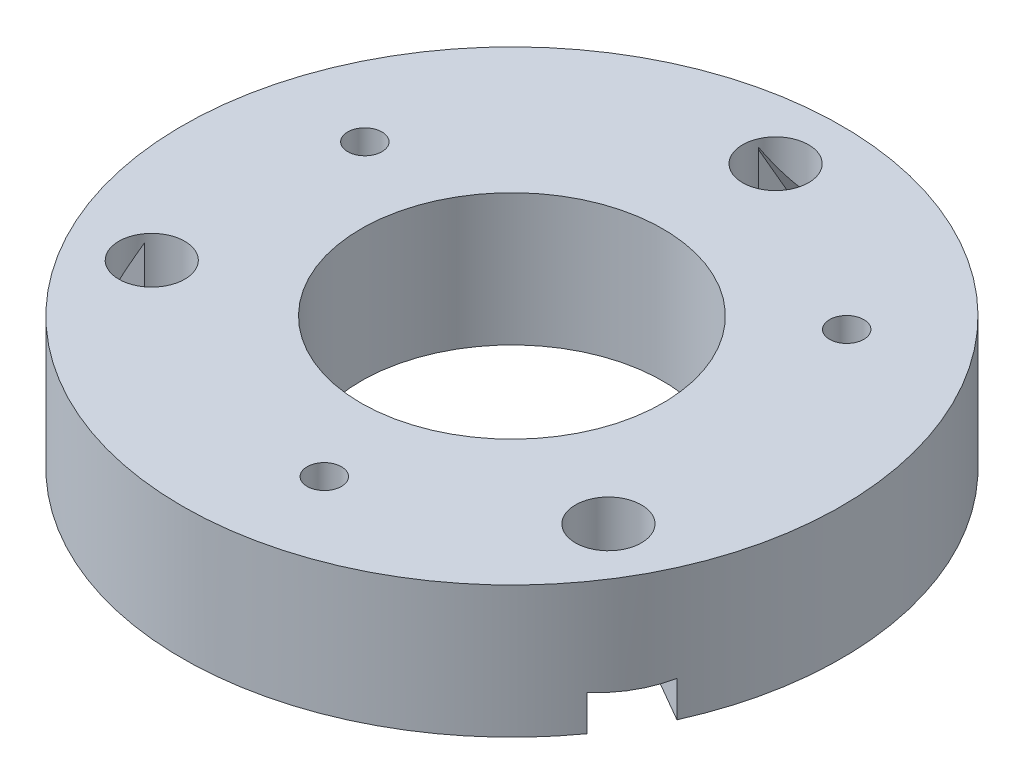
from build123d import *

# Parameters (mm, degrees)
SKETCH1_R           = 63.5
SKETCH1_R_2         = 29.083
SKETCH1_R_3         = 6.35
BOSS_EXTRUDE1_DEPTH = 25.4
CUT_EXTRUDE3_DEPTH  = 6.35
CIRPATTERN1_COUNT   = 3
SKETCH5_R           = 3.302
CUT_EXTRUDE4_DEPTH  = 26.4
CIRPATTERN2_COUNT   = 3


with BuildPart() as part:
    # Sketch1 → Boss-Extrude1 (new body)
    with BuildSketch(Plane(origin=(0, 0, 0), x_dir=(1, 0, 0), z_dir=(0, 1, 0))):
        Circle(SKETCH1_R)
        Circle(SKETCH1_R_2, mode=Mode.SUBTRACT)
        with Locations((0, 50.8)):
            Circle(SKETCH1_R_3, mode=Mode.SUBTRACT)
        with Locations((43.994090512, -25.4)):
            Circle(SKETCH1_R_3, mode=Mode.SUBTRACT)
        with Locations((-43.994090512, -25.4)):
            Circle(SKETCH1_R_3, mode=Mode.SUBTRACT)
    extrude(amount=BOSS_EXTRUDE1_DEPTH)

    # Sketch4 → Cut-Extrude3 (cut, symmetric)
    with BuildSketch(Plane(origin=(0, 0, 0), x_dir=(0, 0, -1), z_dir=(1, 0, 0))):
        Polygon((63.5, 0), (63.5, 6.35), (53.360319725, 23.912441409), (53.360319725, 0), align=None)
    cut_extrude3 = extrude(amount=CUT_EXTRUDE3_DEPTH, both=True, mode=Mode.SUBTRACT)

    # CirPattern1: Cut-Extrude3 ×3 about axis
    cirpattern1_axis = Axis((0, 0, 0), (0, 1, 0))
    for i in range(1, CIRPATTERN1_COUNT):
        add(cut_extrude3.rotate(cirpattern1_axis, i * 360 / CIRPATTERN1_COUNT), mode=Mode.SUBTRACT)

    # Sketch5 → Cut-Extrude4 (cut, through all)
    with BuildSketch(Plane(origin=(0, 25.4, 0), x_dir=(1, 0, 0), z_dir=(0, 1, 0))):
        with Locations((-43.229109276, 14.884976022)):
            Circle(SKETCH5_R)
    cut_extrude4 = extrude(amount=-CUT_EXTRUDE4_DEPTH, mode=Mode.SUBTRACT)

    # CirPattern2: Cut-Extrude4 ×3 about axis
    cirpattern2_axis = Axis((0, 0, 0), (0, 1, 0))
    for i in range(1, CIRPATTERN2_COUNT):
        add(cut_extrude4.rotate(cirpattern2_axis, i * 360 / CIRPATTERN2_COUNT), mode=Mode.SUBTRACT)


solid = part.part
